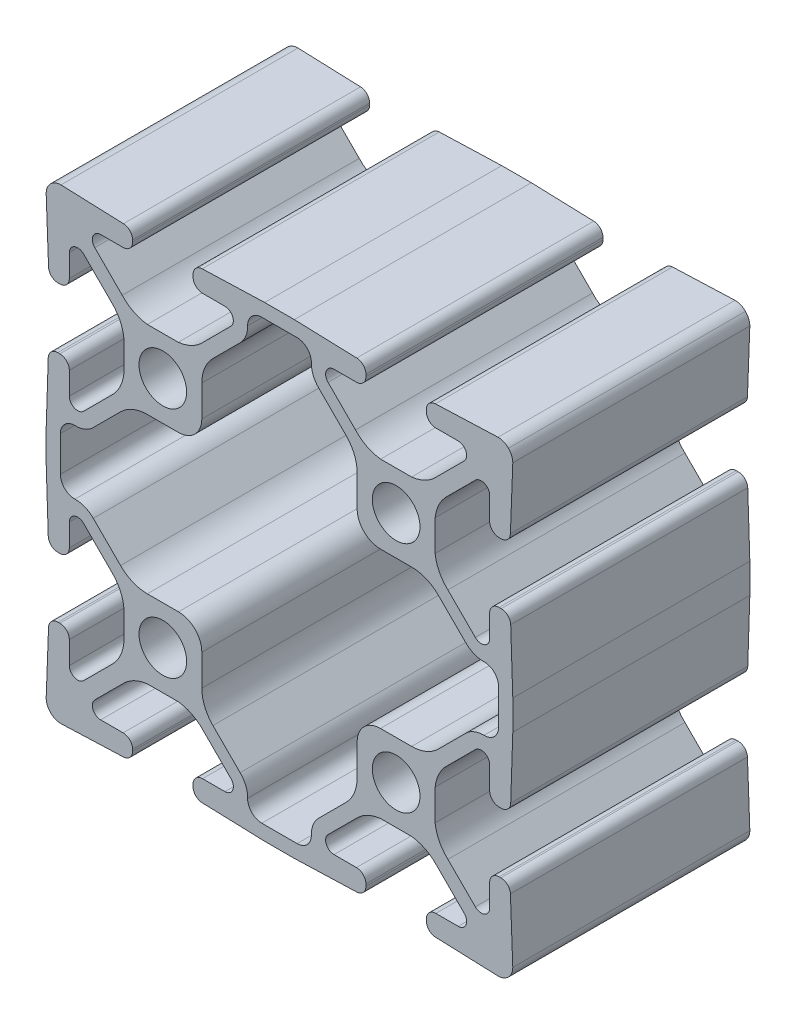
from build123d import *

# Parameters (mm, degrees)
SKETCH1_R      = 2.552699952
EXTRUDE1_DEPTH = 25.4


with BuildPart() as part:
    # Sketch1 → Extrude1 (new body)
    with BuildSketch(Plane.XY):
        with BuildLine():
            Line((14.158480034, 16.677986986), (10.841519496, 16.677986986))
            ThreePointArc((10.841519496, 16.677986986), (9.367961483, 17.114735476), (8.144614283, 18.045081697))
            Line((8.144614283, 18.045081697), (5.206106513, 20.983605341))
            ThreePointArc((5.206106513, 20.983605341), (5.011013242, 21.964415961), (5.842504416, 22.519999696))
            Line((5.842504416, 22.519999696), (8.245487145, 22.51999945))
            ThreePointArc((8.245487145, 22.51999945), (8.963907711, 22.817578991), (9.261487253, 23.535999557))
            Line((9.261487253, 23.535999557), (9.262250551, 23.758352897))
            ThreePointArc((9.262250551, 23.758352897), (8.977738177, 24.466958057), (8.28004927, 24.777278463))
            Line((8.28004927, 24.777278463), (1.58749997, 24.99999953))
            Line((1.58749997, 24.99999953), (-1.58749997, 24.99999953))
            Line((-1.58749997, 24.99999953), (-8.28004927, 24.777278463))
            ThreePointArc((-8.28004927, 24.777278463), (-8.977738177, 24.466958057), (-9.262250551, 23.758352897))
            Line((-9.262250551, 23.758352897), (-9.261487253, 23.535999557))
            ThreePointArc((-9.261487253, 23.535999557), (-8.963907711, 22.817578991), (-8.245487145, 22.51999945))
            Line((-8.245487145, 22.51999945), (-5.842504416, 22.519999696))
            ThreePointArc((-5.842504416, 22.519999696), (-5.011013242, 21.964415961), (-5.206106513, 20.983605341))
            Line((-5.206106513, 20.983605341), (-8.144614283, 18.045081697))
            ThreePointArc((-8.144614283, 18.045081697), (-9.367961483, 17.114735476), (-10.841519496, 16.677986986))
            Line((-10.841519496, 16.677986986), (-14.158480034, 16.677986986))
            ThreePointArc((-14.158480034, 16.677986986), (-15.632038047, 17.114735476), (-16.855385246, 18.045081697))
            Line((-16.855385246, 18.045081697), (-19.793893017, 20.983605341))
            ThreePointArc((-19.793893017, 20.983605341), (-19.988986288, 21.964415961), (-19.157495114, 22.519999696))
            Line((-19.157495114, 22.519999696), (-16.754512385, 22.51999945))
            ThreePointArc((-16.754512385, 22.51999945), (-16.036091819, 22.817578991), (-15.738512277, 23.535999557))
            Line((-15.738512277, 23.535999557), (-15.73785884, 23.726349629))
            ThreePointArc((-15.73785884, 23.726349629), (-16.020691894, 24.433208517), (-16.715217759, 24.745102485))
            Line((-16.715217759, 24.745102485), (-23.413485519, 24.99999953))
            ThreePointArc((-23.413485519, 24.99999953), (-24.020673387, 24.879291654), (-24.535524425, 24.535524425))
            ThreePointArc((-24.535524425, 24.535524425), (-24.879291654, 24.020673387), (-24.99999953, 23.413485519))
            Line((-24.99999953, 23.413485519), (-24.745102485, 16.715217759))
            ThreePointArc((-24.745102485, 16.715217759), (-24.433208517, 16.020691894), (-23.726349629, 15.73785884))
            Line((-23.726349629, 15.73785884), (-23.535999557, 15.738512277))
            ThreePointArc((-23.535999557, 15.738512277), (-22.817578991, 16.036091819), (-22.51999945, 16.754512385))
            Line((-22.51999945, 16.754512385), (-22.519999696, 19.157495114))
            ThreePointArc((-22.519999696, 19.157495114), (-21.964415961, 19.988986288), (-20.983605341, 19.793893017))
            Line((-20.983605341, 19.793893017), (-18.045081697, 16.855385246))
            ThreePointArc((-18.045081697, 16.855385246), (-17.114735476, 15.632038047), (-16.677986986, 14.158480034))
            Line((-16.677986986, 14.158480034), (-16.677986986, 10.841519496))
            ThreePointArc((-16.677986986, 10.841519496), (-17.114735476, 9.367961483), (-18.045081697, 8.144614283))
            Line((-18.045081697, 8.144614283), (-20.983605341, 5.206106513))
            ThreePointArc((-20.983605341, 5.206106513), (-21.964415961, 5.011013242), (-22.519999696, 5.842504416))
            Line((-22.519999696, 5.842504416), (-22.51999945, 8.245487145))
            ThreePointArc((-22.51999945, 8.245487145), (-22.817578991, 8.963907711), (-23.535999557, 9.261487253))
            Line((-23.535999557, 9.261487253), (-23.758352897, 9.262250551))
            ThreePointArc((-23.758352897, 9.262250551), (-24.466958057, 8.977738177), (-24.777278463, 8.28004927))
            Line((-24.777278463, 8.28004927), (-24.99999953, 1.58749997))
            Line((-24.99999953, 1.58749997), (-24.99999953, -1.58749997))
            Line((-24.99999953, -1.58749997), (-24.777278463, -8.28004927))
            ThreePointArc((-24.777278463, -8.28004927), (-24.466958057, -8.977738177), (-23.758352897, -9.262250551))
            Line((-23.758352897, -9.262250551), (-23.535999557, -9.261487253))
            ThreePointArc((-23.535999557, -9.261487253), (-22.817578991, -8.963907711), (-22.51999945, -8.245487145))
            Line((-22.51999945, -8.245487145), (-22.519999696, -5.842504416))
            ThreePointArc((-22.519999696, -5.842504416), (-21.964415961, -5.011013242), (-20.983605341, -5.206106513))
            Line((-20.983605341, -5.206106513), (-18.045081697, -8.144614283))
            ThreePointArc((-18.045081697, -8.144614283), (-17.114735476, -9.367961483), (-16.677986986, -10.841519496))
            Line((-16.677986986, -10.841519496), (-16.677986986, -14.158480034))
            ThreePointArc((-16.677986986, -14.158480034), (-17.114735476, -15.632038047), (-18.045081697, -16.855385246))
            Line((-18.045081697, -16.855385246), (-20.983605341, -19.793893017))
            ThreePointArc((-20.983605341, -19.793893017), (-21.964415961, -19.988986288), (-22.519999696, -19.157495114))
            Line((-22.519999696, -19.157495114), (-22.51999945, -16.754512385))
            ThreePointArc((-22.51999945, -16.754512385), (-22.817578991, -16.036091819), (-23.535999557, -15.738512277))
            Line((-23.535999557, -15.738512277), (-23.726349629, -15.73785884))
            ThreePointArc((-23.726349629, -15.73785884), (-24.433208517, -16.020691894), (-24.745102485, -16.715217759))
            Line((-24.745102485, -16.715217759), (-24.99999953, -23.413485519))
            ThreePointArc((-24.99999953, -23.413485519), (-24.879291654, -24.020673387), (-24.535524425, -24.535524425))
            ThreePointArc((-24.535524425, -24.535524425), (-24.020673387, -24.879291654), (-23.413485519, -24.99999953))
            Line((-23.413485519, -24.99999953), (-16.715217759, -24.745102485))
            ThreePointArc((-16.715217759, -24.745102485), (-16.020691894, -24.433208517), (-15.73785884, -23.726349629))
            Line((-15.73785884, -23.726349629), (-15.738512277, -23.535999557))
            ThreePointArc((-15.738512277, -23.535999557), (-16.036091819, -22.817578991), (-16.754512385, -22.51999945))
            Line((-16.754512385, -22.51999945), (-19.157495114, -22.519999696))
            ThreePointArc((-19.157495114, -22.519999696), (-19.988986288, -21.964415961), (-19.793893017, -20.983605341))
            Line((-19.793893017, -20.983605341), (-16.855385246, -18.045081697))
            ThreePointArc((-16.855385246, -18.045081697), (-15.632038047, -17.114735476), (-14.158480034, -16.677986986))
            Line((-14.158480034, -16.677986986), (-10.841519496, -16.677986986))
            ThreePointArc((-10.841519496, -16.677986986), (-9.367961483, -17.114735476), (-8.144614283, -18.045081697))
            Line((-8.144614283, -18.045081697), (-5.206106513, -20.983605341))
            ThreePointArc((-5.206106513, -20.983605341), (-5.011013242, -21.964415961), (-5.842504416, -22.519999696))
            Line((-5.842504416, -22.519999696), (-8.245487145, -22.51999945))
            ThreePointArc((-8.245487145, -22.51999945), (-8.963907711, -22.817578991), (-9.261487253, -23.535999557))
            Line((-9.261487253, -23.535999557), (-9.262250551, -23.758352897))
            ThreePointArc((-9.262250551, -23.758352897), (-8.977738177, -24.466958057), (-8.28004927, -24.777278463))
            Line((-8.28004927, -24.777278463), (-1.58749997, -24.99999953))
            Line((-1.58749997, -24.99999953), (1.58749997, -24.99999953))
            Line((1.58749997, -24.99999953), (8.28004927, -24.777278463))
            ThreePointArc((8.28004927, -24.777278463), (8.977738177, -24.466958057), (9.262250551, -23.758352897))
            Line((9.262250551, -23.758352897), (9.261487253, -23.535999557))
            ThreePointArc((9.261487253, -23.535999557), (8.963907711, -22.817578991), (8.245487145, -22.51999945))
            Line((8.245487145, -22.51999945), (5.842504416, -22.519999696))
            ThreePointArc((5.842504416, -22.519999696), (5.011013242, -21.964415961), (5.206106513, -20.983605341))
            Line((5.206106513, -20.983605341), (8.144614283, -18.045081697))
            ThreePointArc((8.144614283, -18.045081697), (9.367961483, -17.114735476), (10.841519496, -16.677986986))
            Line((10.841519496, -16.677986986), (14.158480034, -16.677986986))
            ThreePointArc((14.158480034, -16.677986986), (15.632038047, -17.114735476), (16.855385246, -18.045081697))
            Line((16.855385246, -18.045081697), (19.793893017, -20.983605341))
            ThreePointArc((19.793893017, -20.983605341), (19.988986288, -21.964415961), (19.157495114, -22.519999696))
            Line((19.157495114, -22.519999696), (16.754512385, -22.51999945))
            ThreePointArc((16.754512385, -22.51999945), (16.036091819, -22.817578991), (15.738512277, -23.535999557))
            Line((15.738512277, -23.535999557), (15.73785884, -23.726349629))
            ThreePointArc((15.73785884, -23.726349629), (16.020691894, -24.433208517), (16.715217759, -24.745102485))
            Line((16.715217759, -24.745102485), (23.413485519, -24.99999953))
            ThreePointArc((23.413485519, -24.99999953), (24.020673387, -24.879291654), (24.535524425, -24.535524425))
            ThreePointArc((24.535524425, -24.535524425), (24.879291654, -24.020673387), (24.99999953, -23.413485519))
            Line((24.99999953, -23.413485519), (24.745102485, -16.715217759))
            ThreePointArc((24.745102485, -16.715217759), (24.433208517, -16.020691894), (23.726349629, -15.73785884))
            Line((23.726349629, -15.73785884), (23.535999557, -15.738512277))
            ThreePointArc((23.535999557, -15.738512277), (22.817578991, -16.036091819), (22.51999945, -16.754512385))
            Line((22.51999945, -16.754512385), (22.519999696, -19.157495114))
            ThreePointArc((22.519999696, -19.157495114), (21.964415961, -19.988986288), (20.983605341, -19.793893017))
            Line((20.983605341, -19.793893017), (18.045081697, -16.855385246))
            ThreePointArc((18.045081697, -16.855385246), (17.114735476, -15.632038047), (16.677986986, -14.158480034))
            Line((16.677986986, -14.158480034), (16.677986986, -10.841519496))
            ThreePointArc((16.677986986, -10.841519496), (17.114735476, -9.367961483), (18.045081697, -8.144614283))
            Line((18.045081697, -8.144614283), (20.983605341, -5.206106513))
            ThreePointArc((20.983605341, -5.206106513), (21.964415961, -5.011013242), (22.519999696, -5.842504416))
            Line((22.519999696, -5.842504416), (22.51999945, -8.245487145))
            ThreePointArc((22.51999945, -8.245487145), (22.817578991, -8.963907711), (23.535999557, -9.261487253))
            Line((23.535999557, -9.261487253), (23.758352897, -9.262250551))
            ThreePointArc((23.758352897, -9.262250551), (24.466958057, -8.977738177), (24.777278463, -8.28004927))
            Line((24.777278463, -8.28004927), (24.99999953, -1.58749997))
            Line((24.99999953, -1.58749997), (24.99999953, 1.58749997))
            Line((24.99999953, 1.58749997), (24.777278463, 8.28004927))
            ThreePointArc((24.777278463, 8.28004927), (24.466958057, 8.977738177), (23.758352897, 9.262250551))
            Line((23.758352897, 9.262250551), (23.535999557, 9.261487253))
            ThreePointArc((23.535999557, 9.261487253), (22.817578991, 8.963907711), (22.51999945, 8.245487145))
            Line((22.51999945, 8.245487145), (22.519999696, 5.842504416))
            ThreePointArc((22.519999696, 5.842504416), (21.964415961, 5.011013242), (20.983605341, 5.206106513))
            Line((20.983605341, 5.206106513), (18.045081697, 8.144614283))
            ThreePointArc((18.045081697, 8.144614283), (17.114735476, 9.367961483), (16.677986986, 10.841519496))
            Line((16.677986986, 10.841519496), (16.677986986, 14.158480034))
            ThreePointArc((16.677986986, 14.158480034), (17.114735476, 15.632038047), (18.045081697, 16.855385246))
            Line((18.045081697, 16.855385246), (20.983605341, 19.793893017))
            ThreePointArc((20.983605341, 19.793893017), (21.964415961, 19.988986288), (22.519999696, 19.157495114))
            Line((22.519999696, 19.157495114), (22.51999945, 16.754512385))
            ThreePointArc((22.51999945, 16.754512385), (22.817578991, 16.036091819), (23.535999557, 15.738512277))
            Line((23.535999557, 15.738512277), (23.726349629, 15.73785884))
            ThreePointArc((23.726349629, 15.73785884), (24.433208517, 16.020691894), (24.745102485, 16.715217759))
            Line((24.745102485, 16.715217759), (24.99999953, 23.413485519))
            ThreePointArc((24.99999953, 23.413485519), (24.879291654, 24.020673387), (24.535524425, 24.535524425))
            ThreePointArc((24.535524425, 24.535524425), (24.020673387, 24.879291654), (23.413485519, 24.99999953))
            Line((23.413485519, 24.99999953), (16.715217759, 24.745102485))
            ThreePointArc((16.715217759, 24.745102485), (16.020691894, 24.433208517), (15.73785884, 23.726349629))
            Line((15.73785884, 23.726349629), (15.738512277, 23.535999557))
            ThreePointArc((15.738512277, 23.535999557), (16.036091819, 22.817578991), (16.754512385, 22.51999945))
            Line((16.754512385, 22.51999945), (19.157495114, 22.519999696))
            ThreePointArc((19.157495114, 22.519999696), (19.988986288, 21.964415961), (19.793893017, 20.983605341))
            Line((19.793893017, 20.983605341), (16.855385246, 18.045081697))
            ThreePointArc((16.855385246, 18.045081697), (15.632038047, 17.114735476), (14.158480034, 16.677986986))
        make_face()
        with Locations((-12.499999765, -12.499999765)):
            Circle(SKETCH1_R, mode=Mode.SUBTRACT)
        with Locations((-12.499999765, 12.499999765)):
            Circle(SKETCH1_R, mode=Mode.SUBTRACT)
        with Locations((12.499999765, -12.499999765)):
            Circle(SKETCH1_R, mode=Mode.SUBTRACT)
        with Locations((12.499999765, 12.499999765)):
            Circle(SKETCH1_R, mode=Mode.SUBTRACT)
        with BuildLine():
            Line((10.822012497, 8.322012544), (14.158480034, 8.322012544))
            ThreePointArc((14.158480034, 8.322012544), (15.713705474, 8.012658969), (17.032161938, 7.131694525))
            Line((17.032161938, 7.131694525), (19.949420204, 4.2144205))
            ThreePointArc((19.949420204, 4.2144205), (20.851141506, 3.61063891), (21.918418792, 3.414239551))
            ThreePointArc((21.918418792, 3.414239551), (23.017691565, 2.980048222), (23.475999559, 1.890609595))
            Line((23.475999559, 1.890609595), (23.475999559, -1.890609595))
            ThreePointArc((23.475999559, -1.890609595), (23.017691565, -2.980048222), (21.918418792, -3.414239551))
            ThreePointArc((21.918418792, -3.414239551), (20.851141506, -3.61063891), (19.949420204, -4.2144205))
            Line((19.949420204, -4.2144205), (17.032161938, -7.131694525))
            ThreePointArc((17.032161938, -7.131694525), (15.713705474, -8.012658969), (14.158480034, -8.322012544))
            Line((14.158480034, -8.322012544), (10.822012497, -8.322012544))
            ThreePointArc((10.822012497, -8.322012544), (9.054245577, -9.054245577), (8.322012544, -10.822012497))
            Line((8.322012544, -10.822012497), (8.322012544, -14.158480034))
            ThreePointArc((8.322012544, -14.158480034), (8.012658969, -15.713705474), (7.131694525, -17.032161938))
            Line((7.131694525, -17.032161938), (4.2144205, -19.949420204))
            ThreePointArc((4.2144205, -19.949420204), (3.61063891, -20.851141506), (3.414239551, -21.918418792))
            ThreePointArc((3.414239551, -21.918418792), (2.980048222, -23.017691565), (1.890609595, -23.475999559))
            Line((1.890609595, -23.475999559), (-1.890609595, -23.475999559))
            ThreePointArc((-1.890609595, -23.475999559), (-2.980048222, -23.017691565), (-3.414239551, -21.918418792))
            ThreePointArc((-3.414239551, -21.918418792), (-3.61063891, -20.851141506), (-4.2144205, -19.949420204))
            Line((-4.2144205, -19.949420204), (-7.131694525, -17.032161938))
            ThreePointArc((-7.131694525, -17.032161938), (-8.012658969, -15.713705474), (-8.322012544, -14.158480034))
            Line((-8.322012544, -14.158480034), (-8.322012544, -10.822012497))
            ThreePointArc((-8.322012544, -10.822012497), (-9.054245577, -9.054245577), (-10.822012497, -8.322012544))
            Line((-10.822012497, -8.322012544), (-14.158480034, -8.322012544))
            ThreePointArc((-14.158480034, -8.322012544), (-15.713705474, -8.012658969), (-17.032161938, -7.131694525))
            Line((-17.032161938, -7.131694525), (-19.949420204, -4.2144205))
            ThreePointArc((-19.949420204, -4.2144205), (-20.851141506, -3.61063891), (-21.918418792, -3.414239551))
            ThreePointArc((-21.918418792, -3.414239551), (-23.017691565, -2.980048222), (-23.475999559, -1.890609595))
            Line((-23.475999559, -1.890609595), (-23.475999559, 1.890609595))
            ThreePointArc((-23.475999559, 1.890609595), (-23.017691565, 2.980048222), (-21.918418792, 3.414239551))
            ThreePointArc((-21.918418792, 3.414239551), (-20.851141506, 3.61063891), (-19.949420204, 4.2144205))
            Line((-19.949420204, 4.2144205), (-17.032161938, 7.131694525))
            ThreePointArc((-17.032161938, 7.131694525), (-15.713705474, 8.012658969), (-14.158480034, 8.322012544))
            Line((-14.158480034, 8.322012544), (-10.822012497, 8.322012544))
            ThreePointArc((-10.822012497, 8.322012544), (-9.054245577, 9.054245577), (-8.322012544, 10.822012497))
            Line((-8.322012544, 10.822012497), (-8.322012544, 14.158480034))
            ThreePointArc((-8.322012544, 14.158480034), (-8.012658969, 15.713705474), (-7.131694525, 17.032161938))
            Line((-7.131694525, 17.032161938), (-4.2144205, 19.949420204))
            ThreePointArc((-4.2144205, 19.949420204), (-3.61063891, 20.851141506), (-3.414239551, 21.918418792))
            ThreePointArc((-3.414239551, 21.918418792), (-2.980048222, 23.017691565), (-1.890609595, 23.475999559))
            Line((-1.890609595, 23.475999559), (1.890609595, 23.475999559))
            ThreePointArc((1.890609595, 23.475999559), (2.980048222, 23.017691565), (3.414239551, 21.918418792))
            ThreePointArc((3.414239551, 21.918418792), (3.61063891, 20.851141506), (4.2144205, 19.949420204))
            Line((4.2144205, 19.949420204), (7.131694525, 17.032161938))
            ThreePointArc((7.131694525, 17.032161938), (8.012658969, 15.713705474), (8.322012544, 14.158480034))
            Line((8.322012544, 14.158480034), (8.322012544, 10.822012497))
            ThreePointArc((8.322012544, 10.822012497), (9.054245577, 9.054245577), (10.822012497, 8.322012544))
        make_face(mode=Mode.SUBTRACT)
    extrude(amount=EXTRUDE1_DEPTH)


solid = part.part
